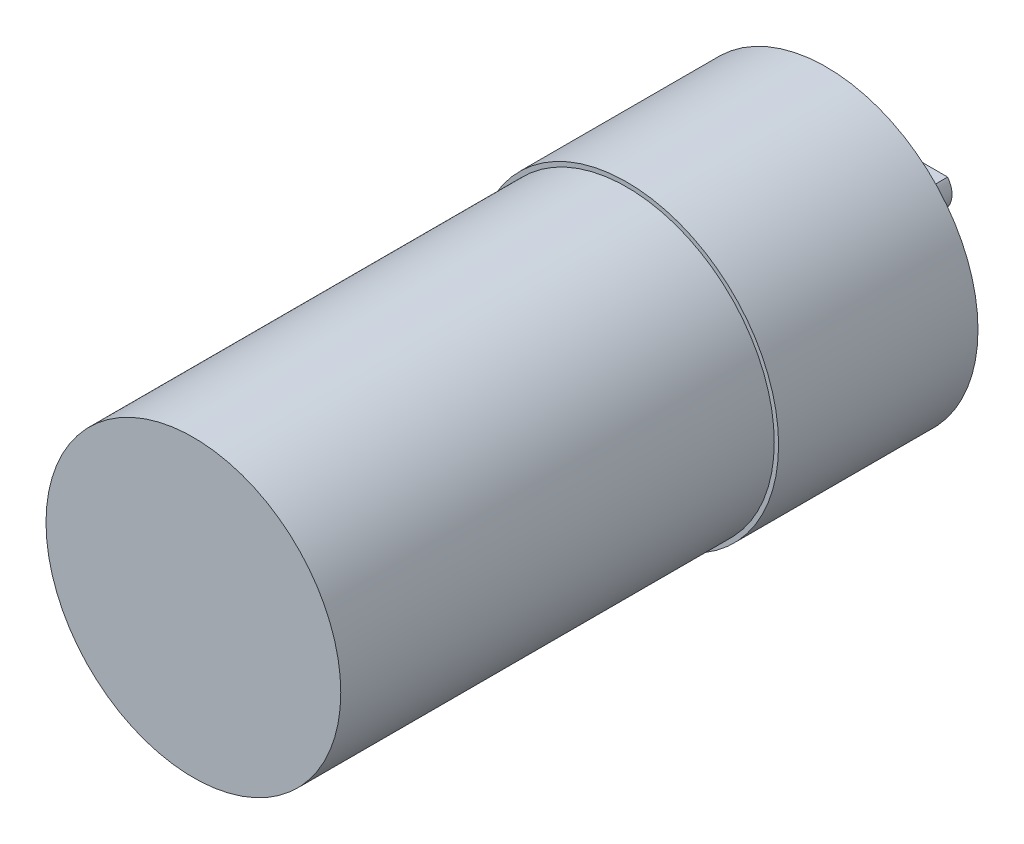
from build123d import *

# Parameters (mm, degrees)
SKETCH1_R           = 17.5
BOSS_EXTRUDE1_DEPTH = 23
SKETCH2_R           = 17
BOSS_EXTRUDE2_DEPTH = 50
SKETCH3_R           = 5
BOSS_EXTRUDE3_DEPTH = 2
BOSS_EXTRUDE4_DEPTH = 10


with BuildPart() as part:
    # Sketch1 → Boss-Extrude1 (new body)
    with BuildSketch(Plane.XY):
        Circle(SKETCH1_R)
    extrude(amount=BOSS_EXTRUDE1_DEPTH)

    # Sketch2 → Boss-Extrude2 (add)
    with BuildSketch(Plane.XY.offset(23)):
        Circle(SKETCH2_R)
    extrude(amount=BOSS_EXTRUDE2_DEPTH)

    # Sketch3 → Boss-Extrude3 (add)
    with BuildSketch(Plane(origin=(0, 0, 0), x_dir=(-1, 0, 0), z_dir=(0, 0, -1))):
        Circle(SKETCH3_R)
    extrude(amount=BOSS_EXTRUDE3_DEPTH)

    # Sketch4 → Boss-Extrude4 (add)
    with BuildSketch(Plane(origin=(0, 0, -2), x_dir=(-1, 0, 0), z_dir=(0, 0, -1))):
        with BuildLine():
            Line((2, 1.5), (-2, 1.5))
            ThreePointArc((-2, 1.5), (-0.790569415, -2.371708245), (2.5, 0))
            ThreePointArc((2.5, 0), (2.371708245, 0.790569415), (2, 1.5))
        make_face()
    extrude(amount=BOSS_EXTRUDE4_DEPTH)


solid = part.part
